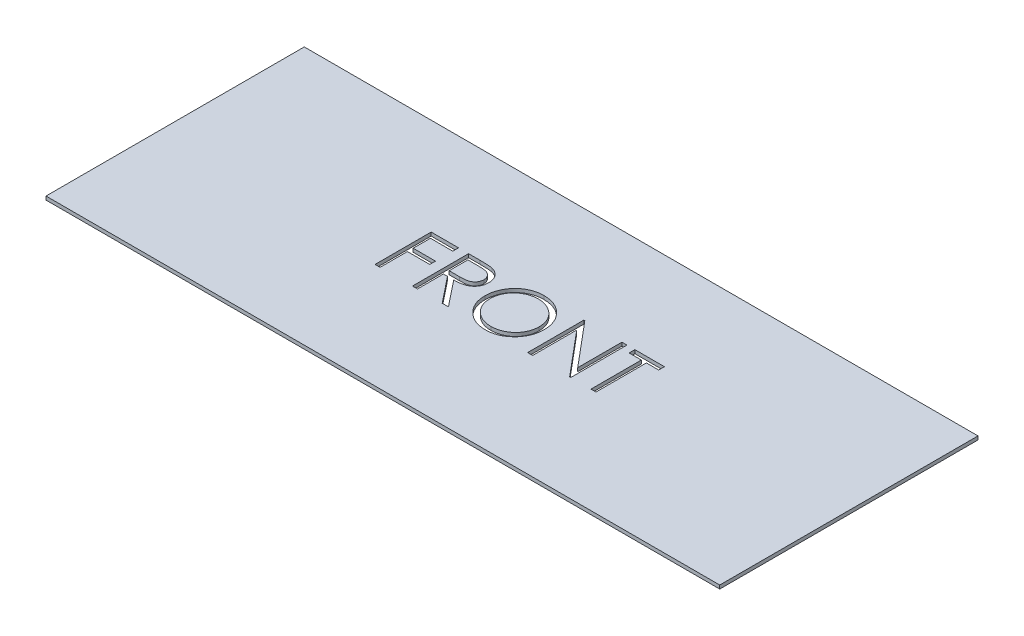
from build123d import *

# Parameters (mm, degrees)
SKETCH1_W           = 38.1
SKETCH1_H           = 14.605
BOSS_EXTRUDE1_DEPTH = 0.2
CUT_EXTRUDE1_DEPTH  = 0.2


with BuildPart() as part:
    # Sketch1 → Boss-Extrude1 (new body)
    with BuildSketch(Plane(origin=(0, 0, 0), x_dir=(1, 0, 0), z_dir=(0, 1, 0))):
        Rectangle(SKETCH1_W, SKETCH1_H)
    extrude(amount=BOSS_EXTRUDE1_DEPTH)

    # Sketch2 → Cut-Extrude1 (cut)
    with BuildSketch(Plane(origin=(0, 0.2, 0), x_dir=(1, 0, 0), z_dir=(0, 1, 0))):
        Polygon((-6.395833275, 1.824678693), (-4.849038403, 1.824678693), (-4.849038403, 1.499037668), (-6.110897378, 1.499037668), (-6.110897378, 0.522114591), (-4.849038403, 0.522114591), (-4.849038403, 0.196473565), (-6.110897378, 0.196473565), (-6.110897378, -1.350321307), (-6.395833275, -1.350321307), align=None)
        with BuildLine():
            Line((-4.279166608, 1.824678693), (-3.643784998, 1.824678693))
            add(Edge.make_bspline(
                [(-3.643784998, 1.824678693), (-3.601384117, 1.824537555), (-3.519969729, 1.824266553), (-3.403335405, 1.822755468), (-3.297356538, 1.818424445), (-3.202088541, 1.814697373), (-3.117533161, 1.807901112), (-3.043431119, 1.801405382), (-2.980123708, 1.792902133), (-2.941800686, 1.78500507), (-2.92444906, 1.781429495)],
                knots=[0, 0, 0, 0, 0.000127205, 0.000244248, 0.000349896, 0.000445402, 0.000530231, 0.00060434, 0.000668562, 0.000721699, 0.000721699, 0.000721699, 0.000721699], degree=3))
            add(Edge.make_bspline(
                [(-2.92444906, 1.781429495), (-2.901220194, 1.775690215), (-2.855257997, 1.764334089), (-2.789081865, 1.740331451), (-2.726022443, 1.712555077), (-2.666341674, 1.679930845), (-2.610338492, 1.642216581), (-2.557435452, 1.600063356), (-2.507392496, 1.553701819), (-2.462233446, 1.50196307), (-2.419653021, 1.447682808), (-2.383740481, 1.388987257), (-2.352782889, 1.327608585), (-2.328135348, 1.262922571), (-2.308288901, 1.195556535), (-2.294295098, 1.124900269), (-2.285902949, 1.05127567), (-2.285048552, 1.001058139), (-2.284615326, 0.97559516)],
                knots=[0, 0, 0, 0, 7.1738e-05, 0.000141945, 0.000210849, 0.000278309, 0.000345694, 0.000413139, 0.000481086, 0.000550014, 0.000618962, 0.000687796, 0.000756061, 0.000824921, 0.000895163, 0.000966511, 0.001040751, 0.001117115, 0.001117115, 0.001117115, 0.001117115], degree=3))
            add(Edge.make_bspline(
                [(-2.284615326, 0.97559516), (-2.285947917, 0.933290458), (-2.288548148, 0.850743027), (-2.312791635, 0.730944942), (-2.352503192, 0.619194635), (-2.407225033, 0.515632813), (-2.476911271, 0.422278156), (-2.560663046, 0.3402811), (-2.65852708, 0.271664894), (-2.749630816, 0.224082707), (-2.830107269, 0.19360914), (-2.896358917, 0.172167586), (-2.968628246, 0.155601374), (-3.046222828, 0.140760398), (-3.129465573, 0.129555646), (-3.218156966, 0.121349093), (-3.312360261, 0.116220063), (-3.377074988, 0.115456244), (-3.410366528, 0.115063309)],
                knots=[0, 0, 0, 0, 0.000126797, 0.000247415, 0.000364897, 0.000481551, 0.000597433, 0.000713022, 0.000831615, 0.000954788, 0.001020224, 0.001089619, 0.001163513, 0.001242474, 0.001326575, 0.001415367, 0.001509635, 0.001609508, 0.001609508, 0.001609508, 0.001609508], degree=3))
            Line((-3.410366528, 0.115063309), (-2.243910198, -1.350321307))
            Line((-2.243910198, -1.350321307), (-2.596263964, -1.350321307))
            Line((-2.596263964, -1.350321307), (-3.762720294, 0.115063309))
            Line((-3.762720294, 0.115063309), (-3.994230711, 0.115063309))
            Line((-3.994230711, 0.115063309), (-3.994230711, -1.350321307))
            Line((-3.994230711, -1.350321307), (-4.279166608, -1.350321307))
            Line((-4.279166608, -1.350321307), (-4.279166608, 1.824678693))
        make_face()
        with BuildLine():
            Line((-3.994230711, 1.499037668), (-3.994230711, 0.440704334))
            Line((-3.994230711, 0.440704334), (-3.412910599, 0.436252211))
            add(Edge.make_bspline(
                [(-3.412910599, 0.436252211), (-3.385768849, 0.436240204), (-3.333160408, 0.43621693), (-3.257050519, 0.439839855), (-3.186184418, 0.443961294), (-3.120833164, 0.450265343), (-3.060967564, 0.458389779), (-3.006617539, 0.468552487), (-2.95769437, 0.480392572), (-2.900636411, 0.498718333), (-2.836921843, 0.527752363), (-2.767678304, 0.569993923), (-2.708711898, 0.623124481), (-2.658893551, 0.683878973), (-2.618861853, 0.75067757), (-2.590638775, 0.822719563), (-2.572729559, 0.898186226), (-2.570617236, 0.950054939), (-2.569551224, 0.976231177)],
                knots=[0, 0, 0, 0, 8.1413e-05, 0.000157801, 0.000228539, 0.000294357, 0.000354712, 0.000409723, 0.000460165, 0.000505621, 0.000589315, 0.00066961, 0.000747992, 0.000826171, 0.000904597, 0.000980539, 0.001057529, 0.001135968, 0.001135968, 0.001135968, 0.001135968], degree=3))
            add(Edge.make_bspline(
                [(-2.569551224, 0.976231177), (-2.570641719, 1.001764141), (-2.572802684, 1.052361157), (-2.590445495, 1.126434733), (-2.620280862, 1.196345466), (-2.660487464, 1.261808963), (-2.709472412, 1.321232024), (-2.766910713, 1.372074798), (-2.831231855, 1.41402967), (-2.891349299, 1.440839715), (-2.945083192, 1.457277011), (-2.99173724, 1.468844138), (-3.044452652, 1.478137335), (-3.10348539, 1.485583218), (-3.16858344, 1.491983061), (-3.24007596, 1.496293603), (-3.31748861, 1.498846179), (-3.371143326, 1.498972353), (-3.398918211, 1.499037668)],
                knots=[0, 0, 0, 0, 7.6536e-05, 0.000151667, 0.000226914, 0.000303706, 0.000381394, 0.000457083, 0.00053294, 0.00061095, 0.000653596, 0.000701416, 0.000755061, 0.00081407, 0.000879888, 0.000951261, 0.001028897, 0.001112218, 0.001112218, 0.001112218, 0.001112218], degree=3))
            Line((-3.398918211, 1.499037668), (-3.994230711, 1.499037668))
        make_face(mode=Mode.SUBTRACT)
        with BuildLine():
            add(Edge.make_bspline(
                [(-0.106890967, 1.90608895), (-0.048100757, 1.904599894), (0.067368067, 1.901675264), (0.237071724, 1.879287792), (0.399082989, 1.840556974), (0.554721615, 1.788974125), (0.702125958, 1.720163361), (0.842405525, 1.636991834), (0.975226546, 1.538588189), (1.098798799, 1.425713105), (1.211880461, 1.302900972), (1.311508229, 1.171838868), (1.395003739, 1.03331924), (1.463570846, 0.887758343), (1.517363156, 0.735485372), (1.554482574, 0.575688527), (1.57819361, 0.409403172), (1.580965637, 0.295985945), (1.582371853, 0.238450729)],
                knots=[0, 0, 0, 0, 0.000176342, 0.00034635, 0.000512345, 0.00067546, 0.000837376, 0.000999356, 0.00116396, 0.001332355, 0.001500709, 0.001664166, 0.001825381, 0.001984993, 0.002146116, 0.00230887, 0.002476442, 0.002648971, 0.002648971, 0.002648971, 0.002648971], degree=3))
            add(Edge.make_bspline(
                [(1.582371853, 0.238450729), (1.580965843, 0.181339331), (1.578194434, 0.06876615), (1.554455614, -0.096463975), (1.517225564, -0.255296249), (1.46407038, -0.40746552), (1.395830125, -0.55313231), (1.311778648, -0.691913333), (1.212771978, -0.823854085), (1.10009862, -0.947509145), (0.977270532, -1.060899708), (0.845525933, -1.159704688), (0.707827707, -1.244725858), (0.5624039, -1.312565334), (0.411183153, -1.366787005), (0.252812045, -1.403755462), (0.088032671, -1.427601565), (-0.024336025, -1.430339791), (-0.081450262, -1.431731563)],
                knots=[0, 0, 0, 0, 0.000171259, 0.000337571, 0.000499706, 0.000660019, 0.000820206, 0.000981421, 0.001145895, 0.001314289, 0.001482643, 0.001646609, 0.00180761, 0.001967222, 0.002127146, 0.002288662, 0.002454344, 0.002625603, 0.002625603, 0.002625603, 0.002625603], degree=3))
            add(Edge.make_bspline(
                [(-0.081450262, -1.431731563), (-0.13898518, -1.430326048), (-0.252401819, -1.427555403), (-0.41889613, -1.403805129), (-0.578805226, -1.366665517), (-0.731671816, -1.3135891), (-0.877581145, -1.24499347), (-1.016818577, -1.161350926), (-1.148825232, -1.062103019), (-1.272506673, -0.949466198), (-1.385672017, -0.82684629), (-1.484332308, -0.69546093), (-1.567993661, -0.557887766), (-1.63635897, -0.413745012), (-1.690483158, -0.263729489), (-1.727408243, -0.106840513), (-1.751298714, 0.056027468), (-1.754051753, 0.16691924), (-1.75544866, 0.223186306)],
                knots=[0, 0, 0, 0, 0.00017253, 0.000340102, 0.000503474, 0.000664388, 0.000824575, 0.000986335, 0.001150809, 0.001319204, 0.001487557, 0.001650632, 0.001811303, 0.001969765, 0.00212849, 0.002288769, 0.002452562, 0.00262128, 0.00262128, 0.00262128, 0.00262128], degree=3))
            add(Edge.make_bspline(
                [(-1.75544866, 0.223186306), (-1.754963669, 0.260953084), (-1.753999806, 0.336010196), (-1.742395913, 0.447467755), (-1.725557799, 0.557132851), (-1.701426064, 0.66469364), (-1.669865051, 0.769886819), (-1.632624998, 0.873437868), (-1.587140995, 0.974297389), (-1.53572355, 1.07294318), (-1.478336053, 1.167837495), (-1.414948766, 1.257535402), (-1.34778811, 1.342789592), (-1.274161318, 1.421390803), (-1.196494971, 1.49562562), (-1.113529157, 1.564353227), (-1.025770121, 1.628193361), (-0.932840247, 1.685724671), (-0.837029384, 1.7377576), (-0.738262593, 1.78240885), (-0.637881274, 1.820732063), (-0.535415272, 1.851793383), (-0.431136686, 1.876315302), (-0.324817924, 1.893013401), (-0.216543688, 1.90464689), (-0.143599134, 1.905606195), (-0.106890967, 1.90608895)],
                knots=[0, 0, 0, 0, 0.000113256, 0.000225083, 0.000335817, 0.000445988, 0.000555461, 0.000665116, 0.000775867, 0.0008871, 0.000998686, 0.001108262, 0.001216432, 0.001323994, 0.001431064, 0.001538557, 0.001646949, 0.001756368, 0.001866213, 0.001973803, 0.002081296, 0.002188332, 0.002294783, 0.002402377, 0.00251104, 0.002621117, 0.002621117, 0.002621117, 0.002621117], degree=3))
        make_face()
        with BuildLine():
            add(Edge.make_bspline(
                [(-0.09289858, 1.580447924), (-0.123028997, 1.580080631), (-0.183001783, 1.579349556), (-0.272159898, 1.569719585), (-0.360145438, 1.555994614), (-0.446976574, 1.536417092), (-0.532289994, 1.509743416), (-0.616880921, 1.479044877), (-0.699977977, 1.441651459), (-0.781306834, 1.399403363), (-0.860151223, 1.352641128), (-0.93454846, 1.300959597), (-1.004691144, 1.245570765), (-1.070407536, 1.18634537), (-1.131504671, 1.122981803), (-1.189185078, 1.056440664), (-1.24113677, 0.98482002), (-1.288748686, 0.910062008), (-1.331355227, 0.832264002), (-1.36924237, 0.752245056), (-1.400234007, 0.66935244), (-1.425509163, 0.584485454), (-1.446463991, 0.497778509), (-1.459739051, 0.408573846), (-1.469474834, 0.317319708), (-1.470164122, 0.255650455), (-1.470512762, 0.224458341)],
                knots=[0, 0, 0, 0, 9.035e-05, 0.000179837, 0.000268716, 0.000357433, 0.000446559, 0.000536708, 0.000627246, 0.000719699, 0.000811541, 0.000902048, 0.000991247, 0.001079509, 0.001167217, 0.001255174, 0.001343459, 0.001432386, 0.001520911, 0.0016094, 0.001697761, 0.001786094, 0.001874954, 0.00196509, 0.002056475, 0.002150004, 0.002150004, 0.002150004, 0.002150004], degree=3))
            add(Edge.make_bspline(
                [(-1.470512762, 0.224458341), (-1.46935628, 0.178591183), (-1.467081123, 0.088356295), (-1.44716247, -0.043876235), (-1.416481107, -0.170956324), (-1.371253353, -0.292188627), (-1.314692439, -0.408615226), (-1.244818045, -0.519203293), (-1.162033018, -0.623982715), (-1.06799539, -0.722221994), (-0.965195506, -0.81188926), (-0.85603653, -0.890596066), (-0.7416879, -0.95718965), (-0.621851423, -1.011441394), (-0.49716687, -1.054430656), (-0.366830806, -1.083893414), (-0.23171146, -1.103284006), (-0.139608652, -1.105146149), (-0.09289858, -1.106090537)],
                knots=[0, 0, 0, 0, 0.000137527, 0.000270558, 0.000400289, 0.000529072, 0.000657927, 0.000787976, 0.000920685, 0.001057889, 0.001195382, 0.001329354, 0.001461022, 0.001591668, 0.001723409, 0.001855936, 0.001992028, 0.002132069, 0.002132069, 0.002132069, 0.002132069], degree=3))
            add(Edge.make_bspline(
                [(-0.09289858, -1.106090537), (-0.061502817, -1.105659187), (0.000764408, -1.10480369), (0.093379632, -1.096187033), (0.184326339, -1.082369551), (0.273476964, -1.062475314), (0.360730329, -1.037576776), (0.446450614, -1.007996909), (0.529724778, -0.971093245), (0.611603345, -0.930319032), (0.689977078, -0.883836889), (0.764794168, -0.833909425), (0.834168807, -0.778602176), (0.899836036, -0.720256732), (0.961184011, -0.65769667), (1.017797876, -0.591003326), (1.069486995, -0.51975573), (1.117080832, -0.445111112), (1.159538078, -0.367100225), (1.196530546, -0.28679116), (1.227914165, -0.204381668), (1.253249309, -0.119752886), (1.273102549, -0.033065544), (1.286782191, 0.055796427), (1.296351132, 0.146655259), (1.29707238, 0.208108614), (1.297435956, 0.239086746)],
                knots=[0, 0, 0, 0, 9.4165e-05, 0.000186757, 0.000278778, 0.000369977, 0.000460573, 0.00055089, 0.000641754, 0.000733627, 0.000825145, 0.000914934, 0.00100324, 0.001091077, 0.00117833, 0.001265874, 0.00135327, 0.001442197, 0.00153128, 0.001619501, 0.001707267, 0.0017956, 0.001884317, 0.001973824, 0.00206521, 0.002158103, 0.002158103, 0.002158103, 0.002158103], degree=3))
            add(Edge.make_bspline(
                [(1.297435956, 0.239086746), (1.297072089, 0.269852954), (1.296350292, 0.330883394), (1.286786762, 0.421108565), (1.273088097, 0.509331121), (1.253346212, 0.595204713), (1.227900715, 0.678751233), (1.196525065, 0.759892211), (1.159526972, 0.838929931), (1.117065226, 0.915669043), (1.069335157, 0.989306127), (1.017179665, 1.059702601), (0.959698242, 1.125536445), (0.898533205, 1.188432917), (0.832156759, 1.247050574), (0.760869578, 1.301408861), (0.685537099, 1.352819617), (0.605774536, 1.399197805), (0.523456806, 1.442027859), (0.438989144, 1.478722698), (0.353328461, 1.50990312), (0.266692588, 1.536497796), (0.178352315, 1.555917937), (0.088904556, 1.569731954), (-0.001526936, 1.579346204), (-0.062344714, 1.580079519), (-0.09289858, 1.580447924)],
                knots=[0, 0, 0, 0, 9.2258e-05, 0.00018301, 0.000271889, 0.000359986, 0.000447102, 0.00053368, 0.000620747, 0.000708715, 0.000796571, 0.000883833, 0.000971308, 0.00105856, 0.001146873, 0.001236684, 0.001327357, 0.001420293, 0.001513311, 0.001605595, 0.001696341, 0.001786684, 0.001877263, 0.001967398, 0.00205815, 0.002149772, 0.002149772, 0.002149772, 0.002149772], degree=3))
        make_face(mode=Mode.SUBTRACT)
        Polygon((2.233653904, -1.350321307), (2.233653904, 1.824678693), (2.293439561, 1.824678693), (4.391025699, -0.674234568), (4.391025699, 1.824678693), (4.675961597, 1.824678693), (4.675961597, -1.350321307), (4.611087799, -1.350321307), (2.518589802, 1.142867796), (2.518589802, -1.350321307), align=None)
        Polygon((5.123718007, 1.499037668), (5.123718007, 1.824678693), (6.792628263, 1.824678693), (6.792628263, 1.499037668), (6.100641084, 1.499037668), (6.100641084, -1.350321307), (5.815705186, -1.350321307), (5.815705186, 1.499037668), align=None)
    extrude(amount=-CUT_EXTRUDE1_DEPTH, mode=Mode.SUBTRACT)


solid = part.part
